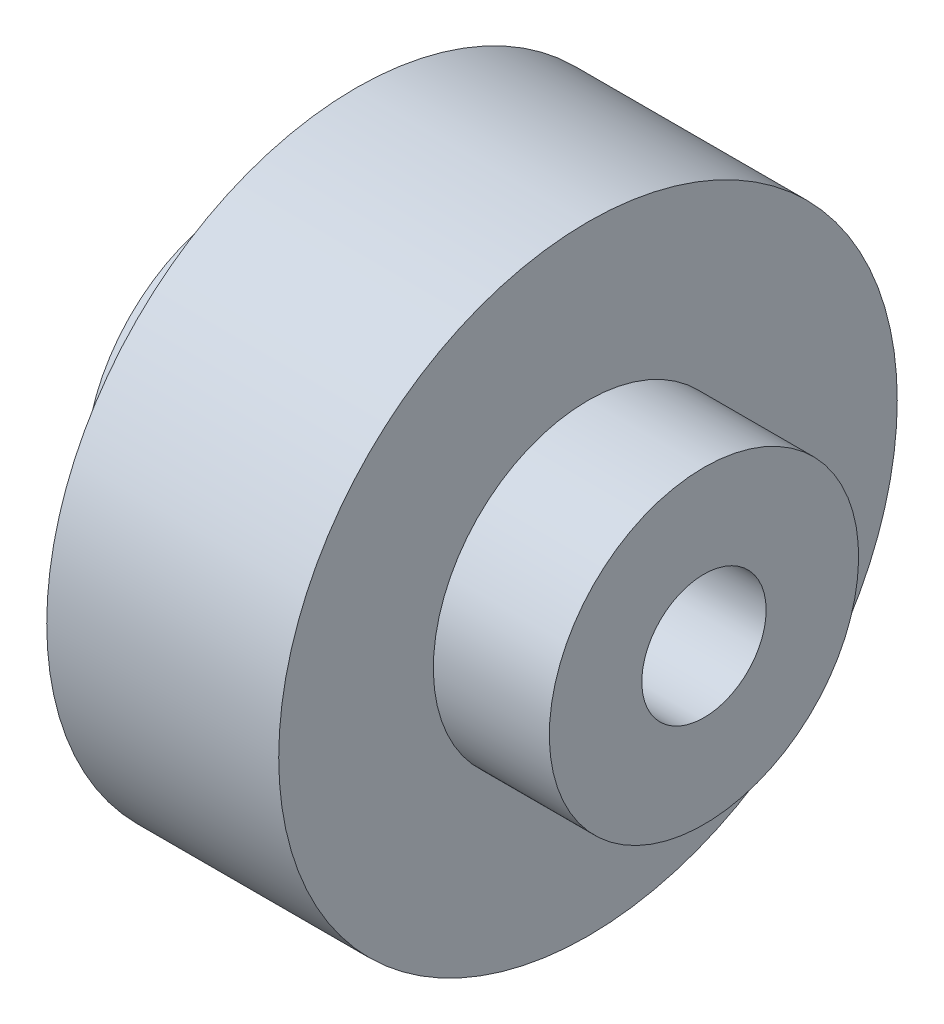
from build123d import *

# Parameters (mm, degrees)
F_1_4_20_TAPPED_HOLE1_D = 5.1054


with BuildPart() as part:
    # Sketch1 → Revolve1 (revolve)
    with BuildSketch(Plane.XY):
        Polygon((0, 0), (0, 6.35), (4.7625, 6.35), (4.7625, 12.7), (14.2875, 12.7), (14.2875, 6.35), (19.05, 6.35), (19.05, 0), align=None)
    revolve(axis=Axis((19.05, 0, 0), (-1, 0, 0)))

    # 1/4-20 Tapped Hole1 (through all)
    with Locations(Plane(origin=(19.05, 0, 0), x_dir=(0, 0, -1), z_dir=(1, 0, 0))):
        with Locations((0, 0)):
            Hole(F_1_4_20_TAPPED_HOLE1_D / 2)


solid = part.part
